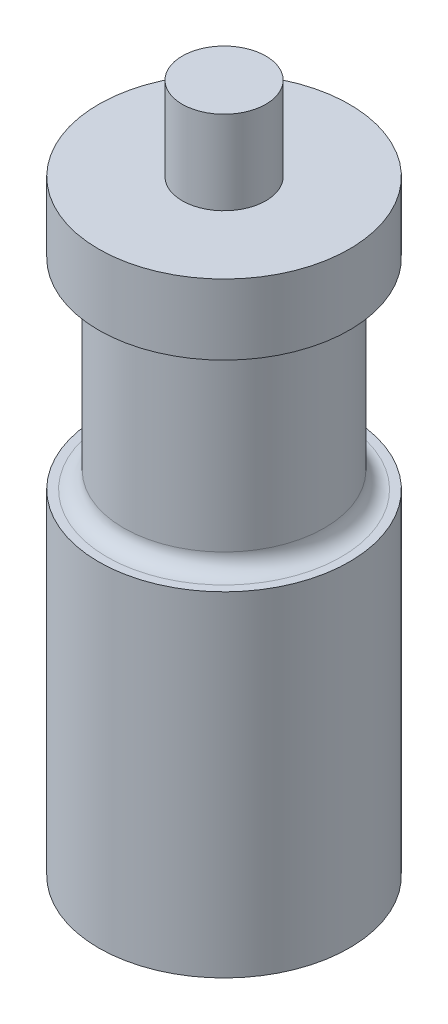
from build123d import *

# Parameters (mm, degrees)
SKETCH1_W   = 7.5
SKETCH1_H   = 20
SKETCH1_W_2 = 6
SKETCH1_H_2 = 12
SKETCH1_W_3 = 2.5
SKETCH1_H_3 = 5
FILLET1_R   = 1


with BuildPart() as part:
    # Sketch1 → Revolve1 (revolve)
    with BuildSketch(Plane.XY):
        with Locations((-3.75, -10)):
            Rectangle(SKETCH1_W, SKETCH1_H)
        with Locations((-3, 6)):
            Rectangle(SKETCH1_W_2, SKETCH1_H_2)
        Polygon((-6, 12), (0, 12), (0, 16.2), (-2.5, 16.2), (-7.5, 16.2), (-7.5, 12), align=None)
        with Locations((-1.25, 18.7)):
            Rectangle(SKETCH1_W_3, SKETCH1_H_3)
    revolve(axis=Axis((0, 25.269315462, 0), (0, -1, 0)))

    # Fillet1
    fillet1_edges = [part.edges().sort_by_distance(p)[0] for p in [
        (6, 0, 0),
        (6, 12, 0),
    ]]
    fillet(fillet1_edges, radius=FILLET1_R)


solid = part.part
